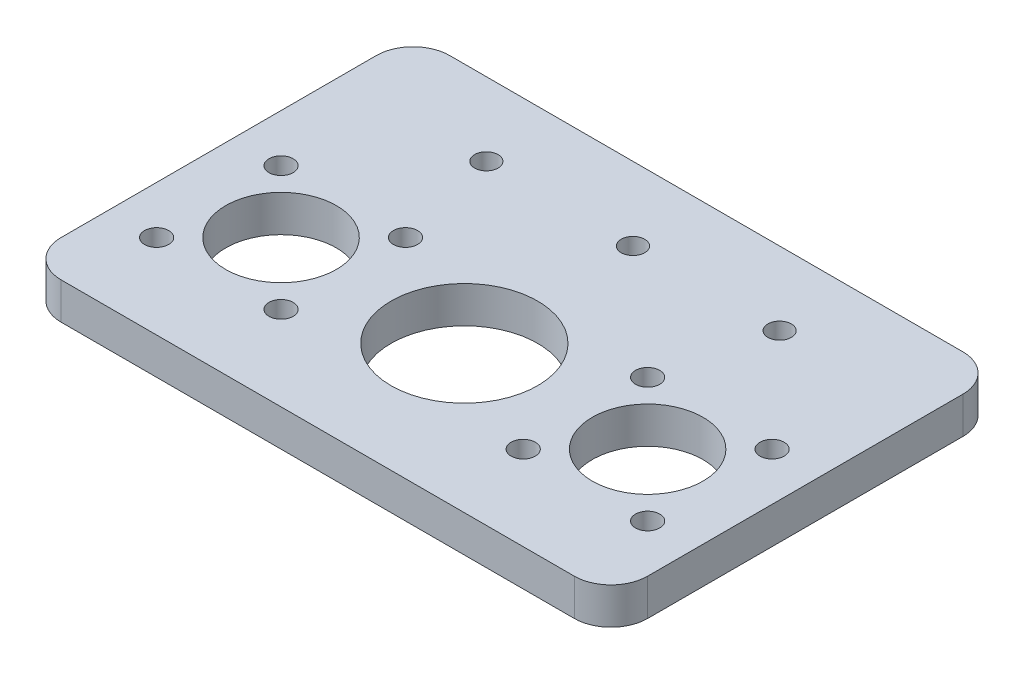
from build123d import *

# Parameters (mm, degrees)
SKETCH_1_R      = 10
SKETCH_1_R_2    = 7.55
SKETCH_1_R_3    = 1.65
SKETCH_1_R_4    = 1.6
EXTRUDE_1_DEPTH = 5


with BuildPart() as part:
    # 草图1 → 凸台-拉伸1 (new body)
    with BuildSketch(Plane(origin=(0, 0, 0), x_dir=(1, 0, 0), z_dir=(0, 1, 0))):
        with BuildLine():
            Line((-35, 33), (35, 33))
            ThreePointArc((35, 33), (38.535533906, 31.535533906), (40, 28))
            Line((40, 28), (40, -15))
            ThreePointArc((40, -15), (38.535533906, -18.535533906), (35, -20))
            Line((35, -20), (-35, -20))
            ThreePointArc((-35, -20), (-38.535533906, -18.535533906), (-40, -15))
            Line((-40, -15), (-40, 28))
            ThreePointArc((-40, 28), (-38.535533906, 31.535533906), (-35, 33))
        make_face()
        Circle(SKETCH_1_R, mode=Mode.SUBTRACT)
        with Locations((-25, 0)):
            Circle(SKETCH_1_R_2, mode=Mode.SUBTRACT)
        with Locations((-33.485281374, 8.485281374)):
            Circle(SKETCH_1_R_3, mode=Mode.SUBTRACT)
        with Locations((-16.514718626, 8.485281374)):
            Circle(SKETCH_1_R_3, mode=Mode.SUBTRACT)
        with Locations((-16.514718626, -8.485281374)):
            Circle(SKETCH_1_R_3, mode=Mode.SUBTRACT)
        with Locations((-33.485281374, -8.485281374)):
            Circle(SKETCH_1_R_3, mode=Mode.SUBTRACT)
        with Locations((25, 0)):
            Circle(SKETCH_1_R_2, mode=Mode.SUBTRACT)
        with Locations((16.514718626, 8.485281374)):
            Circle(SKETCH_1_R_3, mode=Mode.SUBTRACT)
        with Locations((16.514718626, -8.485281374)):
            Circle(SKETCH_1_R_3, mode=Mode.SUBTRACT)
        with Locations((33.485281374, -8.485281374)):
            Circle(SKETCH_1_R_3, mode=Mode.SUBTRACT)
        with Locations((33.485281374, 8.485281374)):
            Circle(SKETCH_1_R_3, mode=Mode.SUBTRACT)
        with Locations((-20, 23)):
            Circle(SKETCH_1_R_4, mode=Mode.SUBTRACT)
        with Locations((0, 23)):
            Circle(SKETCH_1_R_4, mode=Mode.SUBTRACT)
        with Locations((20, 23)):
            Circle(SKETCH_1_R_4, mode=Mode.SUBTRACT)
    extrude(amount=EXTRUDE_1_DEPTH)


solid = part.part
